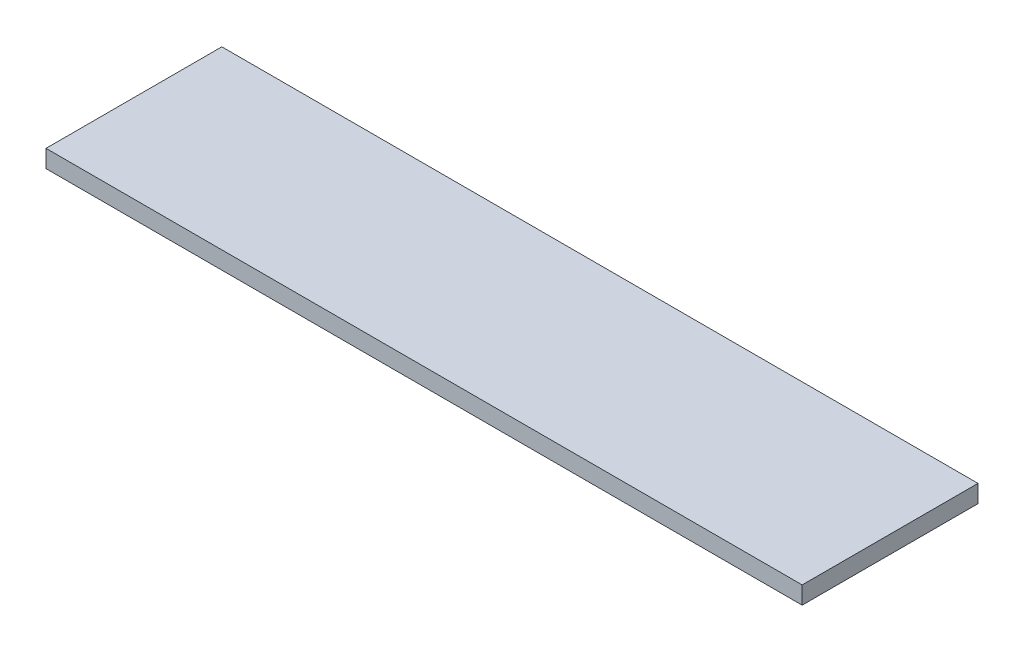
from build123d import *

# Parameters (mm, degrees)
SKETCH1_W           = 430
SKETCH1_H           = 100
BOSS_EXTRUDE1_DEPTH = 10


with BuildPart() as part:
    # Sketch1 → Boss-Extrude1 (new body)
    with BuildSketch(Plane(origin=(0, 0, 0), x_dir=(1, 0, 0), z_dir=(0, 1, 0))):
        Rectangle(SKETCH1_W, SKETCH1_H)
    extrude(amount=BOSS_EXTRUDE1_DEPTH)


solid = part.part
